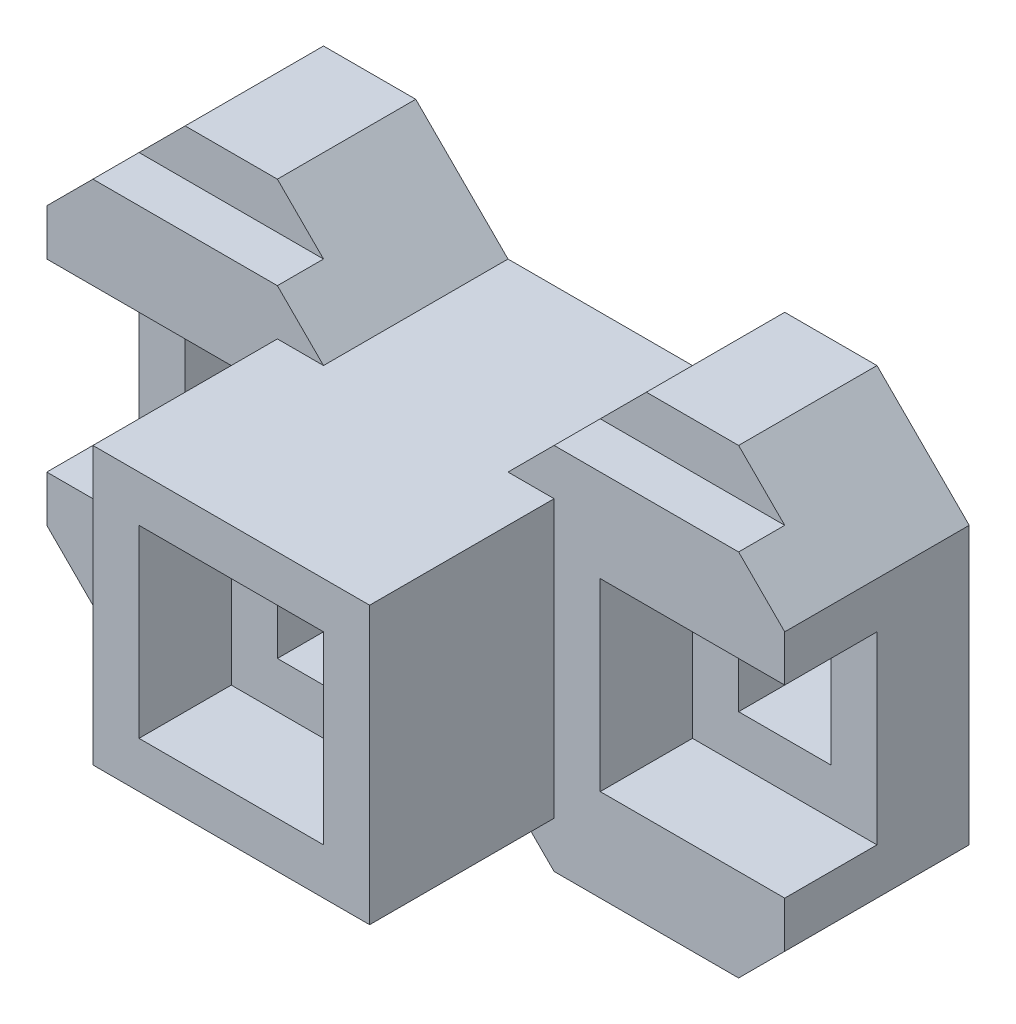
from build123d import *

# Parameters (mm, degrees)
SKETCH1_W           = 60
SKETCH1_H           = 60
BOSS_EXTRUDE1_DEPTH = 80
SKETCH2_W           = 40
SKETCH2_H           = 40
CUT_EXTRUDE1_DEPTH  = 20
SKETCH3_W           = 20
SKETCH3_H           = 20
CUT_EXTRUDE2_DEPTH  = 136
BOSS_EXTRUDE2_DEPTH = 40
CUT_EXTRUDE3_DEPTH  = 10
SKETCH7_W           = 40
SKETCH7_H           = 40
CUT_EXTRUDE4_DEPTH  = 20
SKETCH8_W           = 20
SKETCH8_H           = 20
CUT_EXTRUDE5_DEPTH  = 20
BOSS_EXTRUDE3_DEPTH = 40
CUT_EXTRUDE6_DEPTH  = 10
SKETCH11_W          = 40
SKETCH11_H          = 40
CUT_EXTRUDE7_DEPTH  = 20
SKETCH12_W          = 20
SKETCH12_H          = 20
CUT_EXTRUDE8_DEPTH  = 20


with BuildPart() as part:
    # Sketch1 → Boss-Extrude1 (new body)
    with BuildSketch(Plane.XY):
        with Locations((30, 30)):
            Rectangle(SKETCH1_W, SKETCH1_H)
    extrude(amount=BOSS_EXTRUDE1_DEPTH)

    # Sketch2 → Cut-Extrude1 (cut)
    with BuildSketch(Plane.XY.offset(80)):
        with Locations((30, 30)):
            Rectangle(SKETCH2_W, SKETCH2_H)
    extrude(amount=-CUT_EXTRUDE1_DEPTH, mode=Mode.SUBTRACT)

    # Sketch3 → Cut-Extrude2 (cut)
    with BuildSketch(Plane.XY.offset(60)):
        with Locations((30, 30)):
            Rectangle(SKETCH3_W, SKETCH3_H)
    extrude(amount=-CUT_EXTRUDE2_DEPTH, mode=Mode.SUBTRACT)

    # Sketch5 → Boss-Extrude2 (add)
    with BuildSketch(Plane(origin=(0, 0, 0), x_dir=(-1, 0, 0), z_dir=(0, 0, -1))):
        Polygon((10, 80), (-10, 60), (0, 60), (0, 0), (-10, 0), (10, -20), (30, -20), (50, 0), (50, 60), (30, 80), align=None)
    extrude(amount=-BOSS_EXTRUDE2_DEPTH)

    # Sketch6 → Cut-Extrude3 (cut)
    with BuildSketch(Plane.XY.offset(40)):
        Polygon((-40, 70), (0, 70), (-10, 80), (-30, 80), align=None)
        Polygon((0, -10), (-40, -10), (-30, -20), (-10, -20), align=None)
    extrude(amount=-CUT_EXTRUDE3_DEPTH, mode=Mode.SUBTRACT)

    # Sketch7 → Cut-Extrude4 (cut)
    with BuildSketch(Plane.XY.offset(40)):
        with Locations((-30, 30)):
            Rectangle(SKETCH7_W, SKETCH7_H)
    extrude(amount=-CUT_EXTRUDE4_DEPTH, mode=Mode.SUBTRACT)

    # Sketch8 → Cut-Extrude5 (cut)
    with BuildSketch(Plane.XY.offset(20)):
        with Locations((-30, 30)):
            Rectangle(SKETCH8_W, SKETCH8_H)
    extrude(amount=-CUT_EXTRUDE5_DEPTH, mode=Mode.SUBTRACT)

    # Sketch9 → Boss-Extrude3 (add)
    with BuildSketch(Plane(origin=(0, 0, 0), x_dir=(-1, 0, 0), z_dir=(0, 0, -1))):
        Polygon((-50, 60), (-70, 80), (-90, 80), (-110, 60), (-110, 0), (-90, -20), (-70, -20), (-50, 0), (-60, 0), (-60, 60), align=None)
    extrude(amount=-BOSS_EXTRUDE3_DEPTH)

    # Sketch10 → Cut-Extrude6 (cut)
    with BuildSketch(Plane.XY.offset(40)):
        Polygon((60, 70), (100, 70), (90, 80), (70, 80), align=None)
        Polygon((60, -10), (100, -10), (90, -20), (70, -20), align=None)
    extrude(amount=-CUT_EXTRUDE6_DEPTH, mode=Mode.SUBTRACT)

    # Sketch11 → Cut-Extrude7 (cut)
    with BuildSketch(Plane.XY.offset(40)):
        with Locations((90, 30)):
            Rectangle(SKETCH11_W, SKETCH11_H)
    extrude(amount=-CUT_EXTRUDE7_DEPTH, mode=Mode.SUBTRACT)

    # Sketch12 → Cut-Extrude8 (cut)
    with BuildSketch(Plane.XY.offset(20)):
        with Locations((90, 30)):
            Rectangle(SKETCH12_W, SKETCH12_H)
    extrude(amount=-CUT_EXTRUDE8_DEPTH, mode=Mode.SUBTRACT)


solid = part.part
